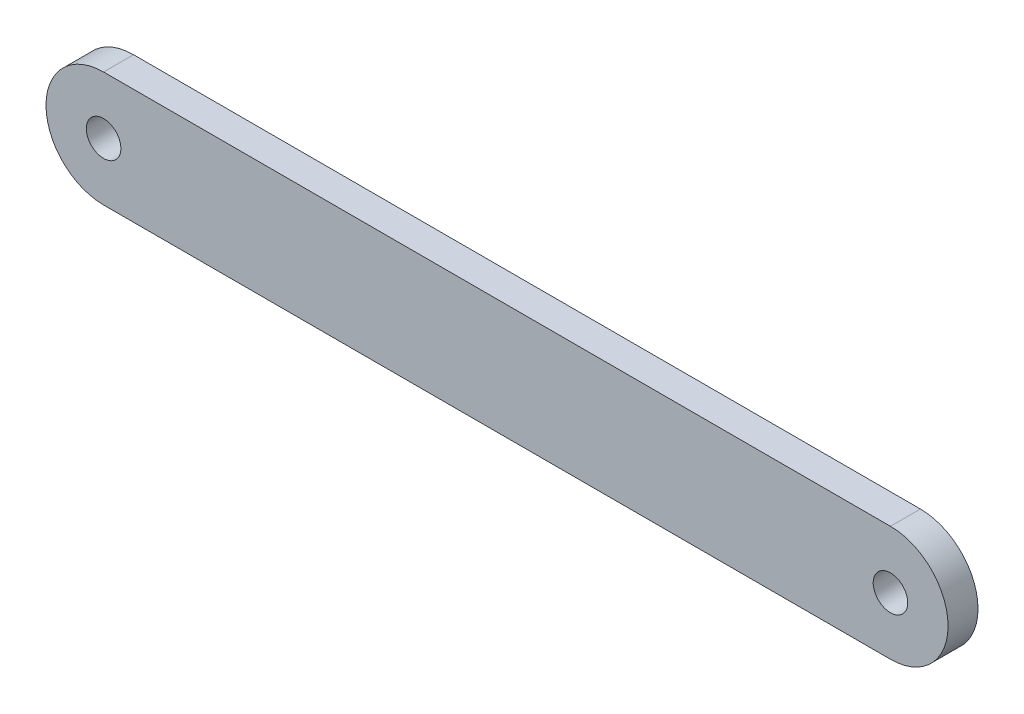
from build123d import *

# Parameters (mm, degrees)
SKETCH_1_R      = 0.75
EXTRUDE_1_DEPTH = 0.65


with BuildPart() as part:
    # 草圖1 → 填料-伸長1 (new body, symmetric)
    with BuildSketch(Plane.XY):
        with BuildLine():
            Line((-17.08, 2.5), (17.08, 2.5))
            ThreePointArc((17.08, 2.5), (19.58, 0), (17.08, -2.5))
            Line((17.08, -2.5), (-17.08, -2.5))
            ThreePointArc((-17.08, -2.5), (-19.58, 0), (-17.08, 2.5))
        make_face()
        with Locations((-17.08, 0)):
            Circle(SKETCH_1_R, mode=Mode.SUBTRACT)
        with Locations((17.08, 0)):
            Circle(SKETCH_1_R, mode=Mode.SUBTRACT)
    extrude(amount=EXTRUDE_1_DEPTH, both=True)


solid = part.part
